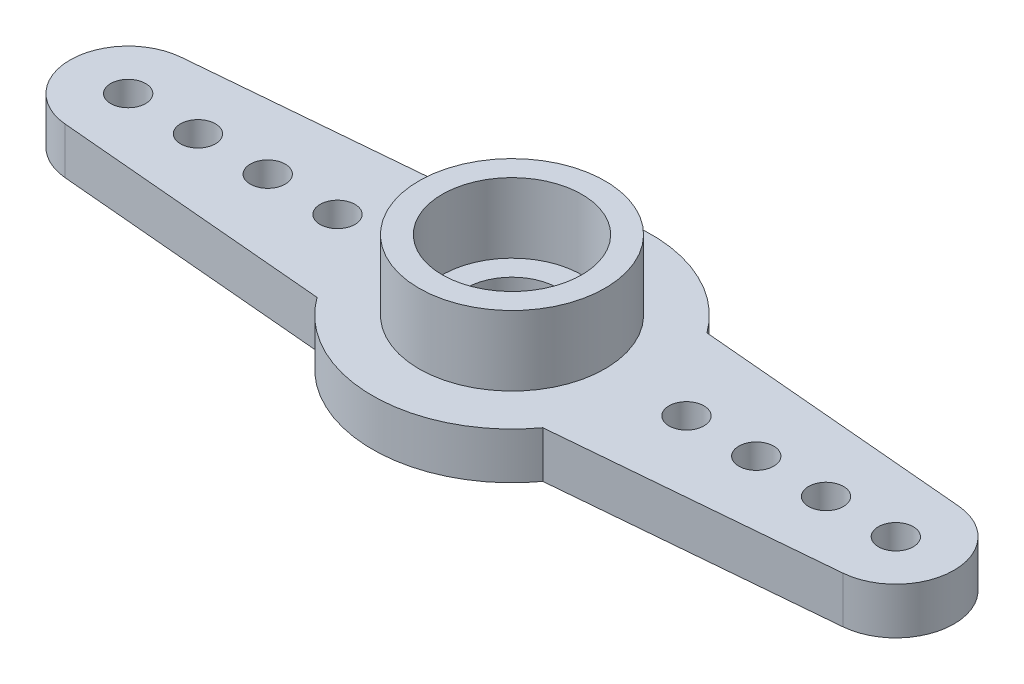
from build123d import *

# Parameters (mm, degrees)
SKETCH1_R           = 2
SKETCH1_R_2         = 0.75
BOSS_EXTRUDE1_DEPTH = 2
SKETCH2_R           = 4
SKETCH2_R_2         = 3
BOSS_EXTRUDE2_DEPTH = 3


with BuildPart() as part:
    # Sketch1 → Boss-Extrude1 (new body)
    with BuildSketch(Plane(origin=(0, 0, 0), x_dir=(1, 0, 0), z_dir=(0, 1, 0))):
        with BuildLine():
            Line((16.717889357, -2.490486745), (4.852765263, -3.528550595))
            ThreePointArc((4.852765263, -3.528550595), (0, -6), (-4.852765263, -3.528550595))
            Line((-4.852765263, -3.528550595), (-16.717889357, -2.490486745))
            ThreePointArc((-16.717889357, -2.490486745), (-19, 0), (-16.717889357, 2.490486745))
            Line((-16.717889357, 2.490486745), (-4.852765263, 3.528550595))
            ThreePointArc((-4.852765263, 3.528550595), (0, 6), (4.852765263, 3.528550595))
            Line((4.852765263, 3.528550595), (16.717889357, 2.490486745))
            ThreePointArc((16.717889357, 2.490486745), (19, 0), (16.717889357, -2.490486745))
        make_face()
        Circle(SKETCH1_R, mode=Mode.SUBTRACT)
        with Locations((7.5, 0)):
            Circle(SKETCH1_R_2, mode=Mode.SUBTRACT)
        with Locations((10.5, 0)):
            Circle(SKETCH1_R_2, mode=Mode.SUBTRACT)
        with Locations((13.5, 0)):
            Circle(SKETCH1_R_2, mode=Mode.SUBTRACT)
        with Locations((16.5, 0)):
            Circle(SKETCH1_R_2, mode=Mode.SUBTRACT)
        with Locations((-16.5, 0)):
            Circle(SKETCH1_R_2, mode=Mode.SUBTRACT)
        with Locations((-13.5, 0)):
            Circle(SKETCH1_R_2, mode=Mode.SUBTRACT)
        with Locations((-10.5, 0)):
            Circle(SKETCH1_R_2, mode=Mode.SUBTRACT)
        with Locations((-7.5, 0)):
            Circle(SKETCH1_R_2, mode=Mode.SUBTRACT)
    extrude(amount=BOSS_EXTRUDE1_DEPTH)

    # Sketch2 → Boss-Extrude2 (add)
    with BuildSketch(Plane(origin=(0, 2, 0), x_dir=(1, 0, 0), z_dir=(0, 1, 0))):
        Circle(SKETCH2_R)
        Circle(SKETCH2_R_2, mode=Mode.SUBTRACT)
    extrude(amount=BOSS_EXTRUDE2_DEPTH)


solid = part.part
